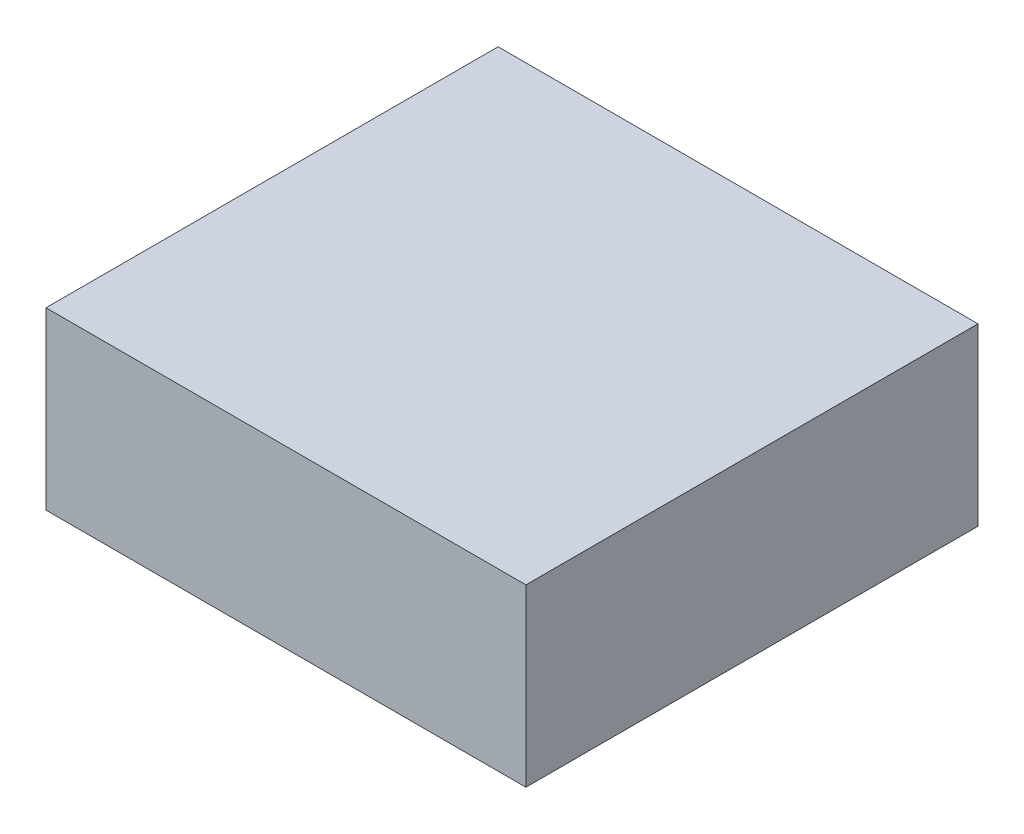
from build123d import *

# Parameters (mm, degrees)
SKETCH2_W           = 34.5
SKETCH2_H           = 32.5
BOSS_EXTRUDE1_DEPTH = 12.6


with BuildPart() as part:
    # Sketch2 → Boss-Extrude1 (new body)
    with BuildSketch(Plane(origin=(0, 0, 0), x_dir=(1, 0, 0), z_dir=(0, 1, 0))):
        Rectangle(SKETCH2_W, SKETCH2_H)
    extrude(amount=BOSS_EXTRUDE1_DEPTH)


solid = part.part
